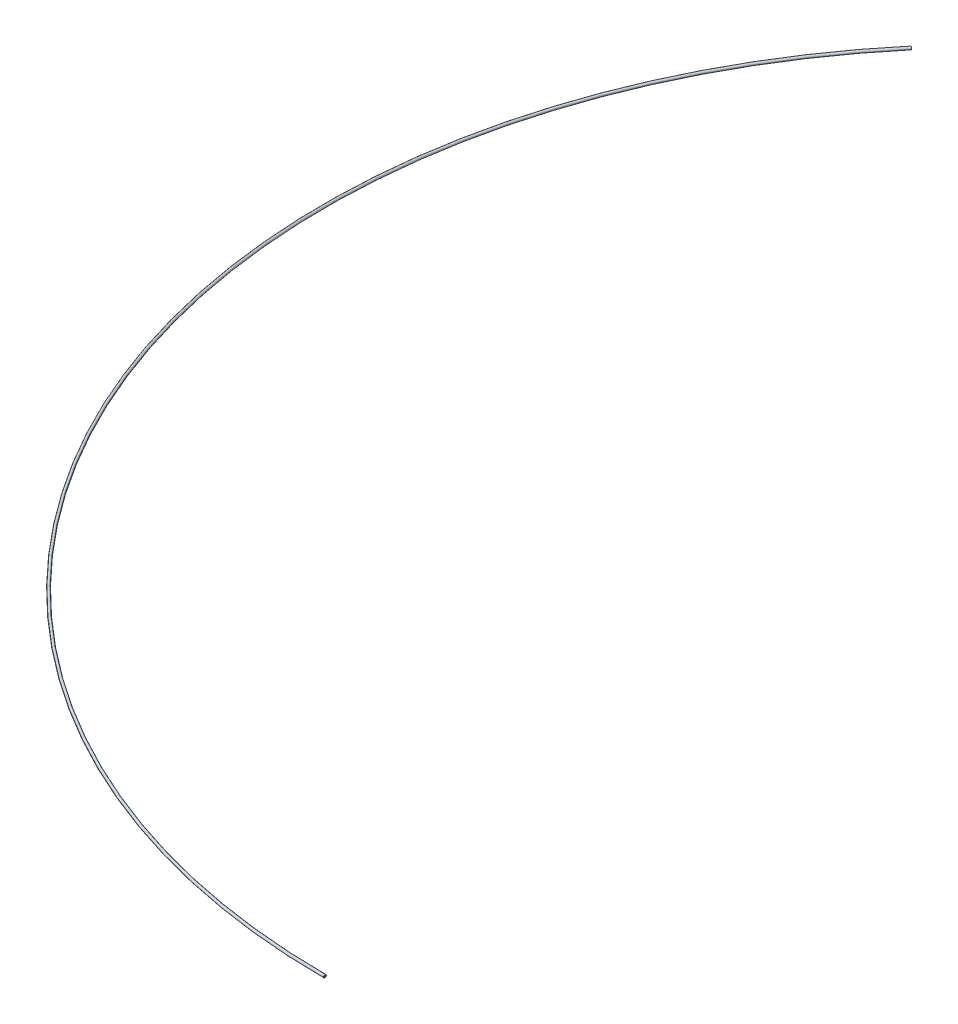
from build123d import *

# Parameters (mm, degrees)
SKETCH2_R   = 0.9
SKETCH2_R_2 = 0.5


with BuildPart() as part:
    # Sweep1: sweep along a path in Sketch1
    with BuildLine(Plane(origin=(0, 0, 0), x_dir=(1, 0, 0), z_dir=(0, 1, 0))) as sweep1_path:
        ThreePointArc((0, -724.856918182), (-399.788632229, -470.002155943), (-337.5, 0))
    # Sketch2 → Sweep1 (sweep)
    with BuildSketch(Plane(origin=(0, 0, 0), x_dir=(0, 0, -1), z_dir=(1, 0, 0))):
        with Locations((-724, 0)):
            Circle(SKETCH2_R)
        with Locations((-724, 0)):
            Circle(SKETCH2_R_2, mode=Mode.SUBTRACT)
    sweep(path=sweep1_path.line)


solid = part.part
